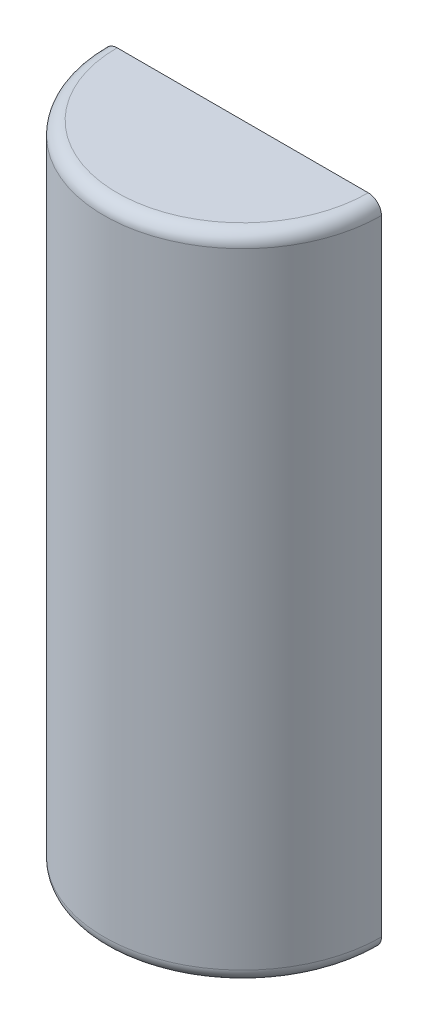
from build123d import *

# Parameters (mm, degrees)
SKETCH1_W      = 133.985
SKETCH1_H      = 628.8
REVOLVE1_ANGLE = 180
FILLET1_R      = 12.7


with BuildPart() as part:
    # Sketch1 → Revolve1 (revolve)
    with BuildSketch(Plane.XY):
        with Locations((-66.9925, 314.4)):
            Rectangle(SKETCH1_W, SKETCH1_H)
    revolve(axis=Axis((0, 0, 0), (0, 1, 0)), revolution_arc=REVOLVE1_ANGLE)

    # Fillet1
    fillet1_edges = [part.edges().sort_by_distance(p)[0] for p in [
        (0, 0, 133.985),
        (0, 628.8, 133.985),
    ]]
    fillet(fillet1_edges, radius=FILLET1_R)


solid = part.part
